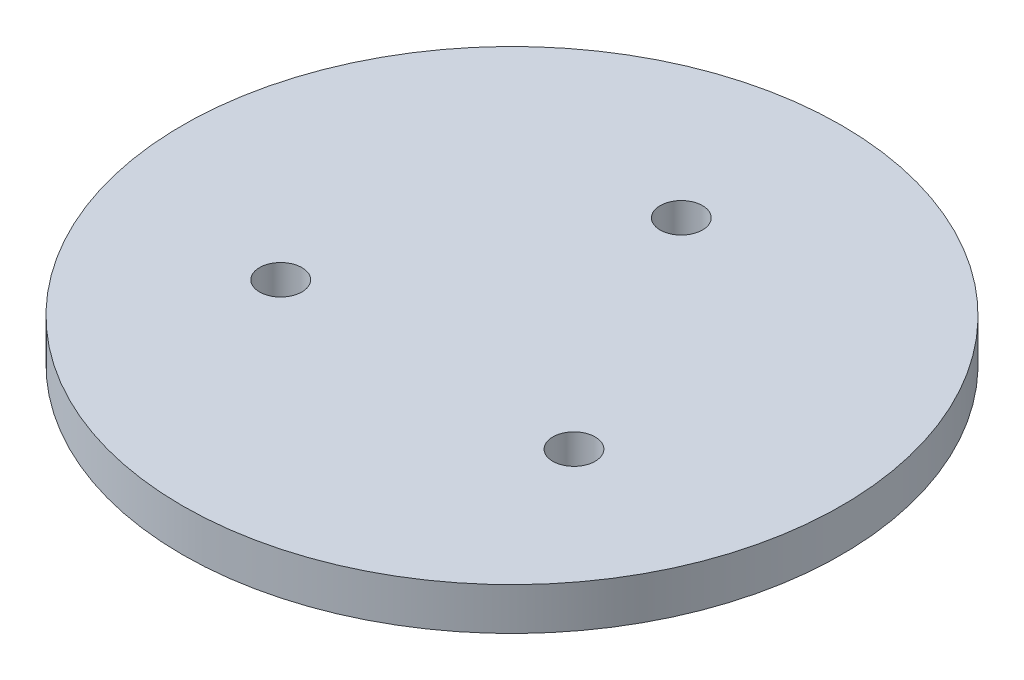
from build123d import *

# Parameters (mm, degrees)
SKETCH_1_R      = 77.853856573
SKETCH_1_R_2    = 5
EXTRUDE_1_DEPTH = 10


with BuildPart() as part:
    # 草图1 → 凸台-拉伸1 (new body)
    with BuildSketch(Plane(origin=(0, 0, 0), x_dir=(1, 0, 0), z_dir=(0, 1, 0))):
        Circle(SKETCH_1_R)
        with Locations((0, 40)):
            Circle(SKETCH_1_R_2, mode=Mode.SUBTRACT)
        with Locations((34.641016151, -20)):
            Circle(SKETCH_1_R_2, mode=Mode.SUBTRACT)
        with Locations((-34.641016151, -20)):
            Circle(SKETCH_1_R_2, mode=Mode.SUBTRACT)
    extrude(amount=EXTRUDE_1_DEPTH)


solid = part.part
